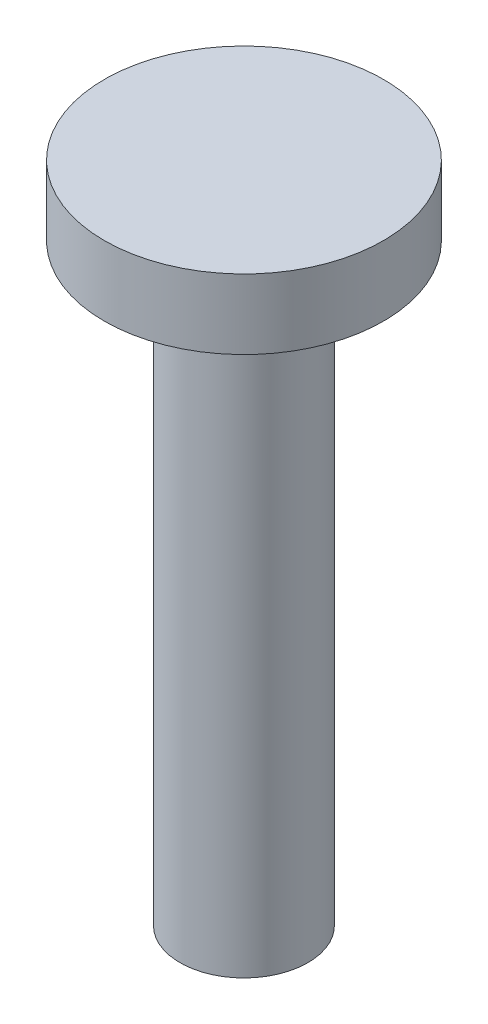
from build123d import *

# Parameters (mm, degrees)
SKETCH1_R           = 10
BOSS_EXTRUDE1_DEPTH = 85
SCALE_1_SCALE       = 0.3
SKETCH_1_R          = 6
EXTRUDE_1_DEPTH     = 3
SKETCH_2_R          = 3
SKETCH_2_R_2        = 2.75
CUT_EXTRUDE_1_DEPTH = 25.5


with BuildPart() as part:
    # Sketch1 → Boss-Extrude1 (new body)
    with BuildSketch(Plane(origin=(0, 0, 0), x_dir=(1, 0, 0), z_dir=(0, 1, 0))):
        Circle(SKETCH1_R)
    extrude(amount=BOSS_EXTRUDE1_DEPTH)


with BuildPart() as part_1:
    # 축척1: scaled about (0, 42.5, 0)
    add(part.part.scale(SCALE_1_SCALE).moved(Location((0, 29.75, 0))))

    # 스케치1 → 보스-돌출1 (add)
    with BuildSketch(Plane(origin=(0, 55.25, 0), x_dir=(1, 0, 0), z_dir=(0, 1, 0))):
        Circle(SKETCH_1_R)
    extrude(amount=EXTRUDE_1_DEPTH)

    # 스케치2 → 컷-돌출1 (cut)
    with BuildSketch(Plane.XZ.offset(-29.75)):
        Circle(SKETCH_2_R)
        Circle(SKETCH_2_R_2, mode=Mode.SUBTRACT)
    extrude(amount=-CUT_EXTRUDE_1_DEPTH, mode=Mode.SUBTRACT)


solid = part_1.part
